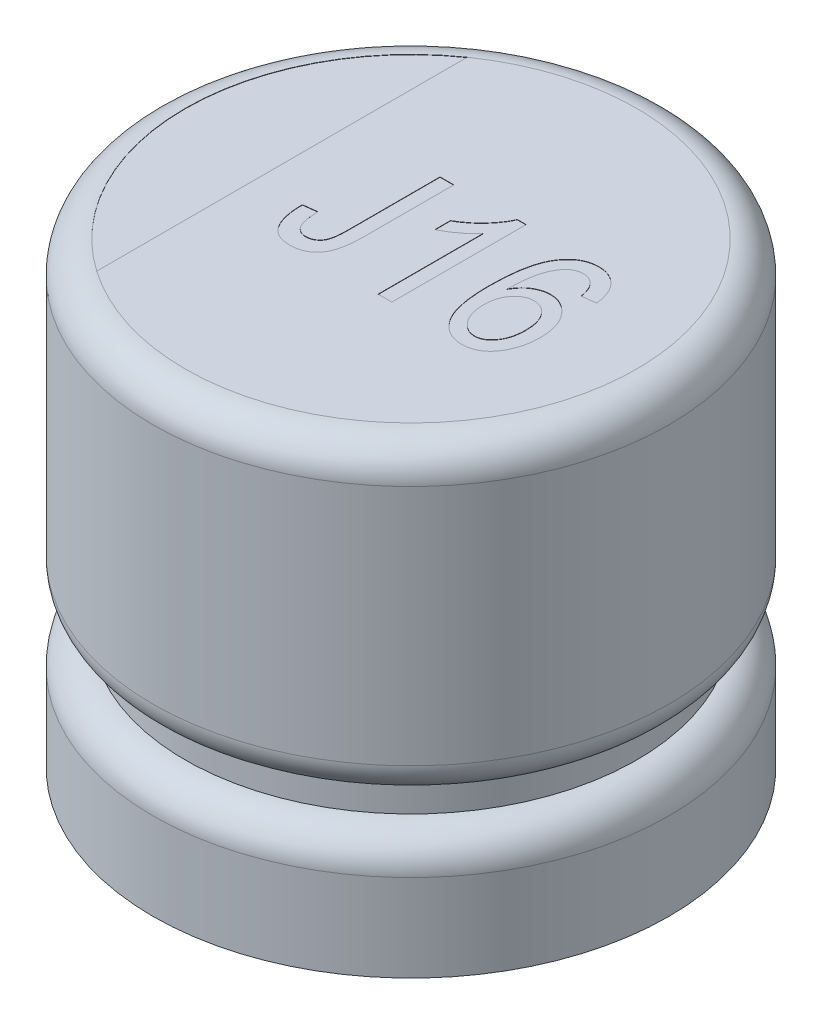
from build123d import *

# Parameters (mm, degrees)
SKETCH1_R           = 8
BOSS_EXTRUDE1_DEPTH = 14.2
FILLET1_R           = 1
CUT_EXTRUDE1_DEPTH  = 0.01
CUT_EXTRUDE2_DEPTH  = 0.01


with BuildPart() as part:
    # Sketch1 → Boss-Extrude1 (new body)
    with BuildSketch(Plane(origin=(0, 0, 0), x_dir=(1, 0, 0), z_dir=(0, 1, 0))):
        Circle(SKETCH1_R)
    extrude(amount=BOSS_EXTRUDE1_DEPTH)

    # Fillet1
    fillet1_edges = [part.edges().sort_by_distance(p)[0] for p in [
        (-8, 14.2, 0),
    ]]
    fillet(fillet1_edges, radius=FILLET1_R)

    # Sketch2 → Cut-Revolve1 (revolve, cut)
    with BuildSketch(Plane.XY):
        with BuildLine():
            Line((-8, 5.7), (-8, 2.7))
            ThreePointArc((-8, 2.7), (-7.707106781, 3.407106781), (-7, 3.7))
            Line((-7, 3.7), (-7, 4.7))
            ThreePointArc((-7, 4.7), (-7.707106781, 4.992893219), (-8, 5.7))
        make_face()
    revolve(axis=Axis((0, -0.75, 0), (0, 1, 0)), mode=Mode.SUBTRACT)

    # Sketch3 → Cut-Extrude1 (cut)
    with BuildSketch(Plane(origin=(0, 14.2, 0), x_dir=(1, 0, 0), z_dir=(0, 1, 0))):
        with BuildLine():
            Line((-4, 5.744562647), (-4, -5.744562647))
            ThreePointArc((-4, -5.744562647), (-7, 0), (-4, 5.744562647))
        make_face()
    extrude(amount=-CUT_EXTRUDE1_DEPTH, mode=Mode.SUBTRACT)

    # Sketch4 → Cut-Extrude2 (cut)
    with BuildSketch(Plane(origin=(0, 14.2, 0), x_dir=(1, 0, 0), z_dir=(0, 1, 0))):
        with BuildLine():
            Line((-2.595736716, -0.772543797), (-2.168795428, -0.719176136))
            add(Edge.make_bspline(
                [(-2.168795428, -0.719176136), (-2.167170895, -0.758389093), (-2.164045061, -0.833840406), (-2.154399785, -0.942236165), (-2.14372796, -1.04120928), (-2.127564576, -1.130218296), (-2.108797279, -1.209728355), (-2.086273218, -1.27960415), (-2.062007703, -1.340611569), (-2.032160498, -1.391578624), (-1.999100063, -1.434444877), (-1.964048117, -1.471928456), (-1.925128512, -1.50257346), (-1.884371502, -1.529319024), (-1.839465953, -1.548059498), (-1.792289279, -1.562366034), (-1.742250288, -1.572119076), (-1.707711783, -1.572742033), (-1.690154219, -1.573058712)],
                knots=[0, 0, 0, 0, 0.00011772, 0.000226511, 0.000326426, 0.000416225, 0.000497731, 0.000571305, 0.000636347, 0.00069427, 0.000747806, 0.000798529, 0.000847755, 0.000896105, 0.000944283, 0.000993084, 0.00104395, 0.001096543, 0.001096543, 0.001096543, 0.001096543], degree=3))
            add(Edge.make_bspline(
                [(-1.690154219, -1.573058712), (-1.665334287, -1.571852802), (-1.616842056, -1.569496742), (-1.546195114, -1.553411372), (-1.480523507, -1.525572848), (-1.420757517, -1.486888767), (-1.367193287, -1.440594884), (-1.323132215, -1.386667997), (-1.28664333, -1.327865618), (-1.271609618, -1.284616144), (-1.2640468, -1.262859183)],
                knots=[0, 0, 0, 0, 7.4444e-05, 0.000145445, 0.000216068, 0.000287314, 0.000358228, 0.000427519, 0.000495591, 0.0005645, 0.0005645, 0.0005645, 0.0005645], degree=3))
            add(Edge.make_bspline(
                [(-1.2640468, -1.262859183), (-1.255314183, -1.228803625), (-1.236046706, -1.15366411), (-1.220505566, -1.026964587), (-1.209399159, -0.877540445), (-1.208603653, -0.770071939), (-1.20817753, -0.712505179)],
                knots=[0, 0, 0, 0, 0.000105378, 0.000232504, 0.00038216, 0.000554803, 0.000554803, 0.000554803, 0.000554803], degree=3))
            Line((-1.20817753, -0.712505179), (-1.20817753, 2.109309896))
            Line((-1.20817753, 2.109309896), (-0.781236242, 2.109309896))
            Line((-0.781236242, 2.109309896), (-0.781236242, -0.67998426))
            add(Edge.make_bspline(
                [(-0.781236242, -0.67998426), (-0.78214197, -0.740591548), (-0.783884319, -0.8571819), (-0.794146383, -1.025107349), (-0.813336118, -1.179070672), (-0.839450139, -1.319350087), (-0.873575682, -1.446004816), (-0.914551907, -1.559345113), (-0.964675121, -1.658319802), (-1.021996781, -1.743902801), (-1.086121458, -1.817377603), (-1.156876877, -1.880442796), (-1.233758946, -1.934155576), (-1.317175104, -1.977575485), (-1.406239485, -2.012290326), (-1.501776809, -2.036145976), (-1.603551446, -2.050497298), (-1.673428424, -2.052393393), (-1.709333222, -2.053367661)],
                knots=[0, 0, 0, 0, 0.000181831, 0.000349789, 0.000504415, 0.000647024, 0.000777498, 0.000897543, 0.001007929, 0.001109459, 0.001205789, 0.001299691, 0.001393143, 0.001486392, 0.001581163, 0.001679252, 0.001781141, 0.001888827, 0.001888827, 0.001888827, 0.001888827], degree=3))
            add(Edge.make_bspline(
                [(-1.709333222, -2.053367661), (-1.744138381, -2.052783085), (-1.811836956, -2.051646043), (-1.909772874, -2.036627625), (-2.00117344, -2.014835548), (-2.08545388, -1.982785508), (-2.162964136, -1.941809049), (-2.233117616, -1.891122797), (-2.298035366, -1.832841995), (-2.333475454, -1.786590477), (-2.351412893, -1.763181004)],
                knots=[0, 0, 0, 0, 0.000104317, 0.000202904, 0.000296543, 0.000385748, 0.000472666, 0.000558745, 0.000644904, 0.000733204, 0.000733204, 0.000733204, 0.000733204], degree=3))
            add(Edge.make_bspline(
                [(-2.351412893, -1.763181004), (-2.371373515, -1.734461029), (-2.412293352, -1.67558427), (-2.460201229, -1.575736303), (-2.503537725, -1.467136645), (-2.536817718, -1.347589317), (-2.563615112, -1.218345032), (-2.58262947, -1.079055434), (-2.593079703, -0.929194412), (-2.594831255, -0.825927452), (-2.595736716, -0.772543797)],
                knots=[0, 0, 0, 0, 0.000104769, 0.00021478, 0.000331227, 0.000455274, 0.000586433, 0.000727004, 0.00087666, 0.001036817, 0.001036817, 0.001036817, 0.001036817], degree=3))
        make_face()
        with BuildLine():
            Line((1.406837858, -2), (0.97989657, -2))
            Line((0.97989657, -2), (0.97989657, 1.25542732))
            add(Edge.make_bspline(
                [(0.97989657, 1.25542732), (0.953676547, 1.225245825), (0.899335576, 1.162694706), (0.805002437, 1.0737383), (0.699878575, 0.982006095), (0.583492503, 0.892993451), (0.46490436, 0.807733741), (0.347776531, 0.732746343), (0.236498913, 0.667501655), (0.161847338, 0.63203815), (0.126013994, 0.615015388)],
                knots=[0, 0, 0, 0, 0.000119871, 0.000248434, 0.000388536, 0.000538317, 0.000687792, 0.000826575, 0.000955448, 0.001074411, 0.001074411, 0.001074411, 0.001074411], degree=3))
            Line((0.126013994, 0.615015388), (0.126013994, 1.095324337))
            add(Edge.make_bspline(
                [(0.126013994, 1.095324337), (0.183601069, 1.12998243), (0.298282114, 1.199001848), (0.458965266, 1.318565767), (0.610760564, 1.447615361), (0.749130884, 1.587502781), (0.873026308, 1.731705768), (0.979368598, 1.875620528), (1.066562541, 2.017717985), (1.109333961, 2.115464643), (1.129993117, 2.162677557)],
                knots=[0, 0, 0, 0, 0.000201529, 0.000401333, 0.000600042, 0.00079875, 0.000990948, 0.001169906, 0.001335222, 0.001489675, 0.001489675, 0.001489675, 0.001489675], degree=3))
            Line((1.129993117, 2.162677557), (1.406837858, 2.162677557))
            Line((1.406837858, 2.162677557), (1.406837858, -2))
        make_face()
        with BuildLine():
            Line((4.608897517, 1.148691998), (4.181956229, 1.095324337))
            add(Edge.make_bspline(
                [(4.181956229, 1.095324337), (4.172087509, 1.1439485), (4.153607916, 1.23499929), (4.113525892, 1.358344262), (4.068867109, 1.461472544), (4.027568435, 1.516193751), (4.008511331, 1.541444628)],
                knots=[0, 0, 0, 0, 0.000148693, 0.000278434, 0.000388858, 0.000483472, 0.000483472, 0.000483472, 0.000483472], degree=3))
            add(Edge.make_bspline(
                [(4.008511331, 1.541444628), (3.994652639, 1.557043989), (3.967705514, 1.587375707), (3.922919277, 1.62666634), (3.876808178, 1.660528442), (3.828316302, 1.688410047), (3.776872021, 1.709255918), (3.72343301, 1.724176543), (3.668069941, 1.733688682), (3.630528091, 1.735049684), (3.611589352, 1.735736269)],
                knots=[0, 0, 0, 0, 6.2546e-05, 0.000121615, 0.000178325, 0.000233969, 0.000288942, 0.00034438, 0.000400174, 0.000456976, 0.000456976, 0.000456976, 0.000456976], degree=3))
            add(Edge.make_bspline(
                [(3.611589352, 1.735736269), (3.582250144, 1.734647698), (3.524123267, 1.73249102), (3.439768968, 1.709239883), (3.35946379, 1.67432715), (3.284330961, 1.623833461), (3.214227173, 1.559544583), (3.147660514, 1.482066928), (3.087134565, 1.389622007), (3.051998215, 1.321646473), (3.033717648, 1.286280499)],
                knots=[0, 0, 0, 0, 8.781e-05, 0.000173969, 0.000260584, 0.000349624, 0.000444084, 0.000545202, 0.000655289, 0.000774681, 0.000774681, 0.000774681, 0.000774681], degree=3))
            add(Edge.make_bspline(
                [(3.033717648, 1.286280499), (3.018375054, 1.252334384), (2.986477465, 1.18175967), (2.949072725, 1.066750605), (2.916202814, 0.940699465), (2.891556425, 0.802505624), (2.869148855, 0.653600921), (2.85486207, 0.492660014), (2.845524654, 0.320493104), (2.844251116, 0.201707574), (2.843595356, 0.140543527)],
                knots=[0, 0, 0, 0, 0.000111683, 0.00023219, 0.000362237, 0.000502232, 0.000653061, 0.000813866, 0.000986721, 0.001170203, 0.001170203, 0.001170203, 0.001170203], degree=3))
            add(Edge.make_bspline(
                [(2.843595356, 0.140543527), (2.86776927, 0.182163709), (2.914806987, 0.263148458), (3.002458577, 0.369258812), (3.096439466, 0.461734528), (3.200800124, 0.5360406), (3.310959349, 0.594340218), (3.424771573, 0.637544507), (3.542314905, 0.663610624), (3.621746151, 0.66678798), (3.661621535, 0.668383049)],
                knots=[0, 0, 0, 0, 0.000144165, 0.000280518, 0.000411438, 0.000538714, 0.000663305, 0.000784423, 0.000902999, 0.001022534, 0.001022534, 0.001022534, 0.001022534], degree=3))
            add(Edge.make_bspline(
                [(3.661621535, 0.668383049), (3.694767614, 0.667230045), (3.760096411, 0.664957547), (3.85649932, 0.64775979), (3.949301969, 0.619160527), (4.039365729, 0.579828425), (4.125795397, 0.528103389), (4.20920449, 0.465616982), (4.288546365, 0.391077357), (4.365210269, 0.307734529), (4.434804731, 0.213853208), (4.495844684, 0.11157826), (4.547931175, 0.001981026), (4.589271628, -0.115908821), (4.622792634, -0.240689863), (4.64606114, -0.373498687), (4.659098397, -0.513780428), (4.661192747, -0.60991232), (4.662265178, -0.659137518)],
                knots=[0, 0, 0, 0, 9.9402e-05, 0.000195915, 0.000292719, 0.000390172, 0.000489992, 0.000594226, 0.000702208, 0.000816131, 0.000933541, 0.001052095, 0.001172948, 0.001296912, 0.001426363, 0.001560168, 0.001700892, 0.001848571, 0.001848571, 0.001848571, 0.001848571], degree=3))
            add(Edge.make_bspline(
                [(4.662265178, -0.659137518), (4.660562749, -0.725939848), (4.657227874, -0.856798427), (4.629277042, -1.048394646), (4.582219638, -1.230143185), (4.528882558, -1.374186168), (4.477646869, -1.482157303), (4.43662234, -1.557546144), (4.393431592, -1.627577358), (4.347702335, -1.692371011), (4.298044233, -1.750415861), (4.247179737, -1.804548146), (4.193068449, -1.852844033), (4.118070656, -1.908896638), (4.019419248, -1.96681827), (3.893396845, -2.016416505), (3.761543294, -2.047767059), (3.671244032, -2.051491739), (3.625765137, -2.053367661)],
                knots=[0, 0, 0, 0, 0.000200339, 0.000392442, 0.00057932, 0.000762705, 0.000852225, 0.000937675, 0.001020055, 0.001098961, 0.0011753, 0.001249025, 0.001321668, 0.001392547, 0.0015297, 0.001663333, 0.001797648, 0.001933936, 0.001933936, 0.001933936, 0.001933936], degree=3))
            add(Edge.make_bspline(
                [(3.625765137, -2.053367661), (3.584800087, -2.051936024), (3.504227771, -2.049120201), (3.386329032, -2.026485879), (3.273561329, -1.991066011), (3.167181511, -1.938917958), (3.064862627, -1.874771497), (2.97016402, -1.79359985), (2.880214334, -1.699202725), (2.795342399, -1.590550649), (2.719013329, -1.46392427), (2.652415727, -1.318855418), (2.596776301, -1.154186479), (2.552936167, -0.970310109), (2.516976597, -0.767644191), (2.491696088, -0.545991439), (2.476814393, -0.304949536), (2.475088027, -0.13799127), (2.474191078, -0.051246504)],
                knots=[0, 0, 0, 0, 0.000122808, 0.000241546, 0.000358897, 0.000476381, 0.000595977, 0.000720254, 0.000849418, 0.000986692, 0.001132991, 0.001291928, 0.001464652, 0.001653548, 0.001858506, 0.002081816, 0.002322439, 0.002582655, 0.002582655, 0.002582655, 0.002582655], degree=3))
            add(Edge.make_bspline(
                [(2.474191078, -0.051246504), (2.474980569, 0.044953245), (2.476501402, 0.230267154), (2.492826468, 0.497609568), (2.517528017, 0.743521177), (2.55431625, 0.967906848), (2.599964385, 1.171128296), (2.657402758, 1.352747927), (2.72407159, 1.513559897), (2.803387762, 1.65252756), (2.890830589, 1.772476364), (2.983492949, 1.876528617), (3.08162573, 1.965450204), (3.186292361, 2.037957013), (3.297768281, 2.093262417), (3.414406609, 2.134018466), (3.537543687, 2.157616433), (3.621497623, 2.160973228), (3.664123144, 2.162677557)],
                knots=[0, 0, 0, 0, 0.000288562, 0.000555871, 0.000803217, 0.001029686, 0.001237627, 0.001427504, 0.001600503, 0.001758853, 0.001906297, 0.002045073, 0.002176163, 0.002302684, 0.002425746, 0.002548371, 0.002672334, 0.002800189, 0.002800189, 0.002800189, 0.002800189], degree=3))
            add(Edge.make_bspline(
                [(3.664123144, 2.162677557), (3.695004397, 2.161796423), (3.755877381, 2.160059536), (3.845453891, 2.148717619), (3.930726298, 2.127377835), (4.012486735, 2.099121305), (4.089955993, 2.062101215), (4.164325231, 2.017981847), (4.233313374, 1.96373261), (4.299350807, 1.903135081), (4.360450784, 1.834767988), (4.414766759, 1.75816123), (4.462934975, 1.674520801), (4.506036796, 1.583874975), (4.541454276, 1.485439904), (4.570409404, 1.379692234), (4.594210109, 1.266972739), (4.603915947, 1.188809615), (4.608897517, 1.148691998)],
                knots=[0, 0, 0, 0, 9.2653e-05, 0.000182638, 0.00027021, 0.00035592, 0.000441712, 0.000527373, 0.000614771, 0.000704465, 0.000796012, 0.000889264, 0.000985662, 0.001085256, 0.001189982, 0.001299028, 0.001413996, 0.001535226, 0.001535226, 0.001535226, 0.001535226], degree=3))
        make_face()
        with BuildLine():
            add(Edge.make_bspline(
                [(2.901132366, -0.643293993), (2.901741955, -0.679451266), (2.902930774, -0.749965045), (2.913087973, -0.8530929), (2.929854085, -0.95053429), (2.951846555, -1.043157443), (2.982279707, -1.129643521), (3.017893416, -1.211579072), (3.061525554, -1.287217183), (3.110563112, -1.357338719), (3.164128741, -1.419976404), (3.220646103, -1.474804309), (3.278570809, -1.521868465), (3.339605961, -1.559635174), (3.402132354, -1.590419626), (3.467710948, -1.61091944), (3.534900558, -1.624084151), (3.580396983, -1.625643223), (3.603250655, -1.626426373)],
                knots=[0, 0, 0, 0, 0.000108454, 0.000211507, 0.000310485, 0.000404934, 0.000496705, 0.000585181, 0.000672579, 0.000758175, 0.000841567, 0.000919407, 0.000994158, 0.001064959, 0.001134331, 0.001202632, 0.001270504, 0.001339008, 0.001339008, 0.001339008, 0.001339008], degree=3))
            add(Edge.make_bspline(
                [(3.603250655, -1.626426373), (3.623588752, -1.625550112), (3.664041496, -1.623807217), (3.72369875, -1.6120862), (3.781104524, -1.591277286), (3.837437407, -1.563901201), (3.891539192, -1.527377882), (3.944628353, -1.484091369), (3.99425889, -1.43129807), (4.043812393, -1.372938004), (4.088130277, -1.306055069), (4.128908209, -1.233882641), (4.160639133, -1.154387818), (4.188852742, -1.070270065), (4.208897842, -0.979321741), (4.225405575, -0.883144416), (4.233004589, -0.780445937), (4.234535324, -0.710288913), (4.23532389, -0.674147172)],
                knots=[0, 0, 0, 0, 6.1015e-05, 0.00012136, 0.000181491, 0.000243769, 0.000308758, 0.000376875, 0.00044882, 0.000525799, 0.000606283, 0.000689139, 0.000774002, 0.000862604, 0.000955043, 0.001053061, 0.001155134, 0.001263589, 0.001263589, 0.001263589, 0.001263589], degree=3))
            add(Edge.make_bspline(
                [(4.23532389, -0.674147172), (4.234564607, -0.638834489), (4.233091715, -0.570333377), (4.22510764, -0.470233611), (4.2099953, -0.376374683), (4.189739657, -0.288251104), (4.161561863, -0.207156175), (4.12951732, -0.131281302), (4.089997674, -0.06186485), (4.045014265, 0.001307532), (3.996277028, 0.057882956), (3.94382003, 0.106837897), (3.889285328, 0.148619047), (3.831446959, 0.182372307), (3.77158506, 0.209598327), (3.707986463, 0.227479487), (3.642381231, 0.240000472), (3.597473653, 0.240959612), (3.574899085, 0.241441761)],
                knots=[0, 0, 0, 0, 0.000105954, 0.000205534, 0.000300949, 0.000390953, 0.000476391, 0.000558183, 0.00063772, 0.000715463, 0.000790534, 0.00086133, 0.000930375, 0.000996161, 0.001061862, 0.001127037, 0.00119394, 0.001261565, 0.001261565, 0.001261565, 0.001261565], degree=3))
            add(Edge.make_bspline(
                [(3.574899085, 0.241441761), (3.552598527, 0.240979548), (3.508509004, 0.240065725), (3.444042916, 0.227375339), (3.381297151, 0.209487177), (3.3213389, 0.181995565), (3.262608258, 0.148816824), (3.206168692, 0.107600392), (3.1532504, 0.057691104), (3.101400083, 0.002370546), (3.054172673, -0.059744356), (3.013079516, -0.127663896), (2.978955542, -0.200794332), (2.950463777, -0.278898345), (2.927853625, -0.362539229), (2.912360019, -0.451581568), (2.903113435, -0.545813647), (2.901805016, -0.610195629), (2.901132366, -0.643293993)],
                knots=[0, 0, 0, 0, 6.6793e-05, 0.000132054, 0.000196429, 0.00026213, 0.000329359, 0.000398575, 0.00047116, 0.00054728, 0.000625833, 0.000704773, 0.000784972, 0.000867542, 0.000953915, 0.001044535, 0.001138378, 0.001237664, 0.001237664, 0.001237664, 0.001237664], degree=3))
        make_face(mode=Mode.SUBTRACT)
    extrude(amount=-CUT_EXTRUDE2_DEPTH, mode=Mode.SUBTRACT)


solid = part.part
